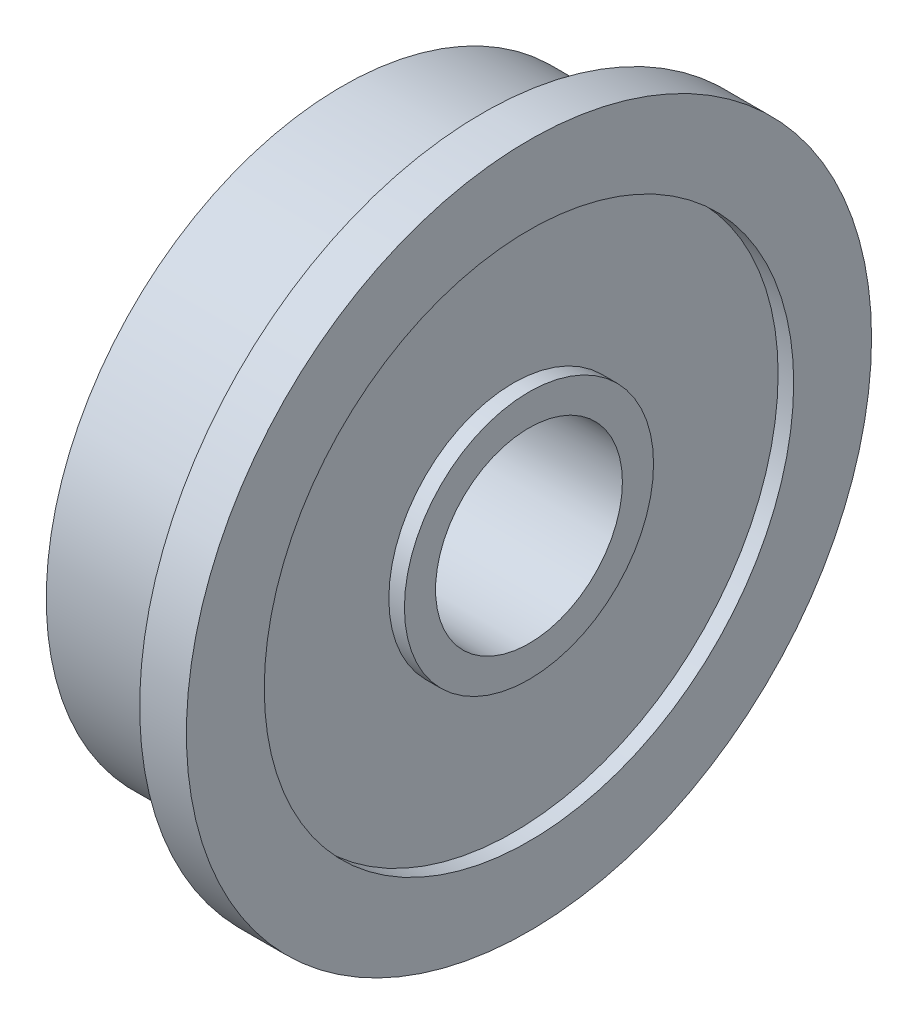
from build123d import *


with BuildPart() as part:
    # Sketch1 → Revolve1 (revolve)
    with BuildSketch(Plane.XY):
        Polygon((-4.5, 3), (1.5, 3), (1.5, 4), (1, 4), (1, 8.5), (1.5, 8.5), (1.5, 11), (0, 11), (0, 9.5), (-4.5, 9.5), (-4.5, 8.5), (-4, 8.5), (-4, 4), (-4.5, 4), align=None)
    revolve(axis=Axis((0, 0, 0), (-1, 0, 0)))


solid = part.part
